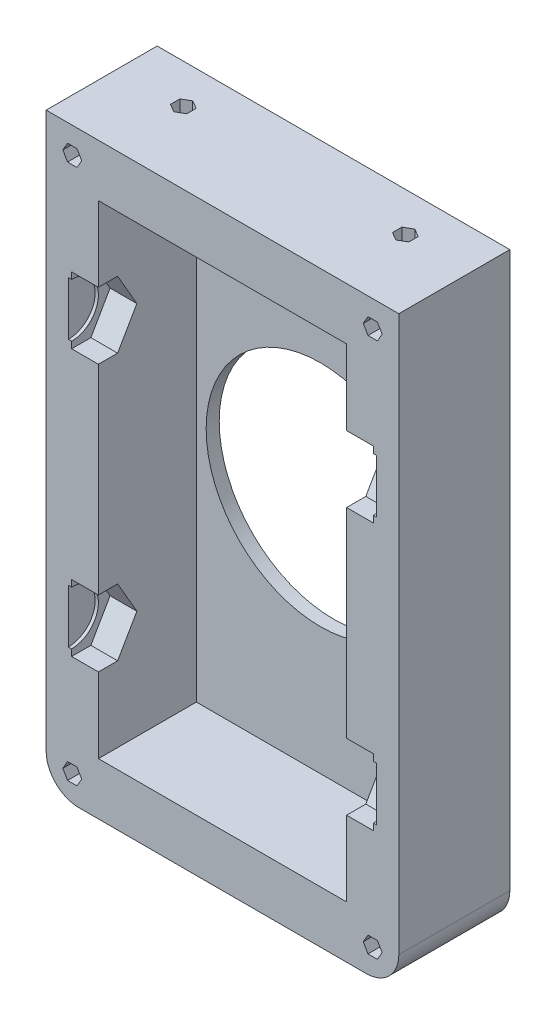
from build123d import *

# Parameters (mm, degrees)
SKETCH1_W           = 54
SKETCH1_H           = 90
SKETCH1_W_2         = 38
SKETCH1_H_2         = 74
BOSS_EXTRUDE1_DEPTH = 30
CUT_EXTRUDE1_DEPTH  = 4.1
SKETCH5_R           = 4.1
CUT_EXTRUDE2_DEPTH  = 0.5
CUT_EXTRUDE3_DEPTH  = 4.1
SKETCH7_R           = 4.1
CUT_EXTRUDE4_DEPTH  = 0.5
SKETCH8_W           = 54
SKETCH8_H           = 90
BOSS_EXTRUDE2_DEPTH = 2
SKETCH9_W           = 54
SKETCH9_H           = 90
BOSS_EXTRUDE3_DEPTH = 2
SKETCH10_W          = 54
SKETCH10_H          = 90
CUT_EXTRUDE5_DEPTH  = 17
SKETCH11_R          = 17.5
CUT_EXTRUDE6_DEPTH  = 3
CUT_EXTRUDE7_DEPTH  = 18
CUT_EXTRUDE8_DEPTH  = 5
FILLET1_R           = 5


with BuildPart() as part:
    # Sketch1 → Boss-Extrude1 (new body)
    with BuildSketch(Plane.XY):
        with Locations((27, 45)):
            Rectangle(SKETCH1_W, SKETCH1_H)
        with Locations((27, 45)):
            Rectangle(SKETCH1_W_2, SKETCH1_H_2, mode=Mode.SUBTRACT)
    extrude(amount=BOSS_EXTRUDE1_DEPTH)

    # Sketch2 → Cut-Extrude1 (cut)
    with BuildSketch(Plane.ZY.offset(-46)):
        Polygon((20.888972746, 65.4), (17.944486373, 70.5), (12.055513627, 70.5), (9.111027254, 65.4), (12.055513627, 60.3), (17.944486373, 60.3), align=None)
        Polygon((20.888972746, 24.6), (17.944486373, 29.7), (12.055513627, 29.7), (9.111027254, 24.6), (12.055513627, 19.5), (17.944486373, 19.5), align=None)
    extrude(amount=-CUT_EXTRUDE1_DEPTH, mode=Mode.SUBTRACT)

    # Sketch5 → Cut-Extrude2 (cut)
    with BuildSketch(Plane.ZY.offset(-50.1)):
        with Locations((15, 65.4)):
            Circle(SKETCH5_R)
        with Locations((15, 24.6)):
            Circle(SKETCH5_R)
    extrude(amount=-CUT_EXTRUDE2_DEPTH, mode=Mode.SUBTRACT)

    # Sketch6 → Cut-Extrude3 (cut)
    with BuildSketch(Plane(origin=(8, 0, 0), x_dir=(0, 0, -1), z_dir=(1, 0, 0))):
        Polygon((-9.111027254, 65.4), (-12.055513627, 70.5), (-17.944486373, 70.5), (-20.888972746, 65.4), (-17.944486373, 60.3), (-12.055513627, 60.3), align=None)
        Polygon((-9.111027254, 24.6), (-12.055513627, 29.7), (-17.944486373, 29.7), (-20.888972746, 24.6), (-17.944486373, 19.5), (-12.055513627, 19.5), align=None)
    extrude(amount=-CUT_EXTRUDE3_DEPTH, mode=Mode.SUBTRACT)

    # Sketch7 → Cut-Extrude4 (cut)
    with BuildSketch(Plane(origin=(3.9, 0, 0), x_dir=(0, 0, -1), z_dir=(1, 0, 0))):
        with Locations((-15, 65.4)):
            Circle(SKETCH7_R)
        with Locations((-15, 24.6)):
            Circle(SKETCH7_R)
    extrude(amount=-CUT_EXTRUDE4_DEPTH, mode=Mode.SUBTRACT)

    # Sketch8 → Boss-Extrude2 (add)
    with BuildSketch(Plane.XY.offset(30)):
        with Locations((27, 45)):
            Rectangle(SKETCH8_W, SKETCH8_H)
    extrude(amount=BOSS_EXTRUDE2_DEPTH)

    # Sketch9 → Boss-Extrude3 (add)
    with BuildSketch(Plane(origin=(0, 0, 0), x_dir=(-1, 0, 0), z_dir=(0, 0, -1))):
        with Locations((-27, 45)):
            Rectangle(SKETCH9_W, SKETCH9_H)
    extrude(amount=BOSS_EXTRUDE3_DEPTH)

    # Sketch10 → Cut-Extrude5 (cut)
    with BuildSketch(Plane.XY.offset(32)):
        with Locations((27, 45)):
            Rectangle(SKETCH10_W, SKETCH10_H)
    extrude(amount=-CUT_EXTRUDE5_DEPTH, mode=Mode.SUBTRACT)

    # Sketch11 → Cut-Extrude6 (cut, through all)
    with BuildSketch(Plane.XY):
        with Locations((27, 45)):
            Circle(SKETCH11_R)
    extrude(amount=-CUT_EXTRUDE6_DEPTH, mode=Mode.SUBTRACT)

    # Sketch12 → Cut-Extrude7 (cut, through all)
    with BuildSketch(Plane.XY.offset(15)):
        Polygon((5.443375673, 86), (4.721687836, 87.25), (3.278312164, 87.25), (2.556624327, 86), (3.278312164, 84.75), (4.721687836, 84.75), align=None)
        Polygon((51.443375673, 86), (50.721687836, 87.25), (49.278312164, 87.25), (48.556624327, 86), (49.278312164, 84.75), (50.721687836, 84.75), align=None)
        Polygon((3.278312164, 2.75), (4.721687836, 2.75), (5.443375673, 4), (4.721687836, 5.25), (3.278312164, 5.25), (2.556624327, 4), align=None)
        Polygon((50.721687836, 5.25), (49.278312164, 5.25), (48.556624327, 4), (49.278312164, 2.75), (50.721687836, 2.75), (51.443375673, 4), align=None)
    extrude(amount=-CUT_EXTRUDE7_DEPTH, mode=Mode.SUBTRACT)

    # Sketch13 → Cut-Extrude8 (cut)
    with BuildSketch(Plane(origin=(0, 90, 0), x_dir=(1, 0, 0), z_dir=(0, 1, 0))):
        Polygon((10, -2.556624327), (8.75, -3.278312164), (8.75, -4.721687836), (10, -5.443375673), (11.25, -4.721687836), (11.25, -3.278312164), align=None)
        Polygon((44, -2.556624327), (42.75, -3.278312164), (42.75, -4.721687836), (44, -5.443375673), (45.25, -4.721687836), (45.25, -3.278312164), align=None)
    extrude(amount=-CUT_EXTRUDE8_DEPTH, mode=Mode.SUBTRACT)

    # Fillet1
    fillet1_edges = [part.edges().sort_by_distance(p)[0] for p in [
        (0, 0, 6.5),
        (54, 0, 6.5),
    ]]
    fillet(fillet1_edges, radius=FILLET1_R)


solid = part.part
